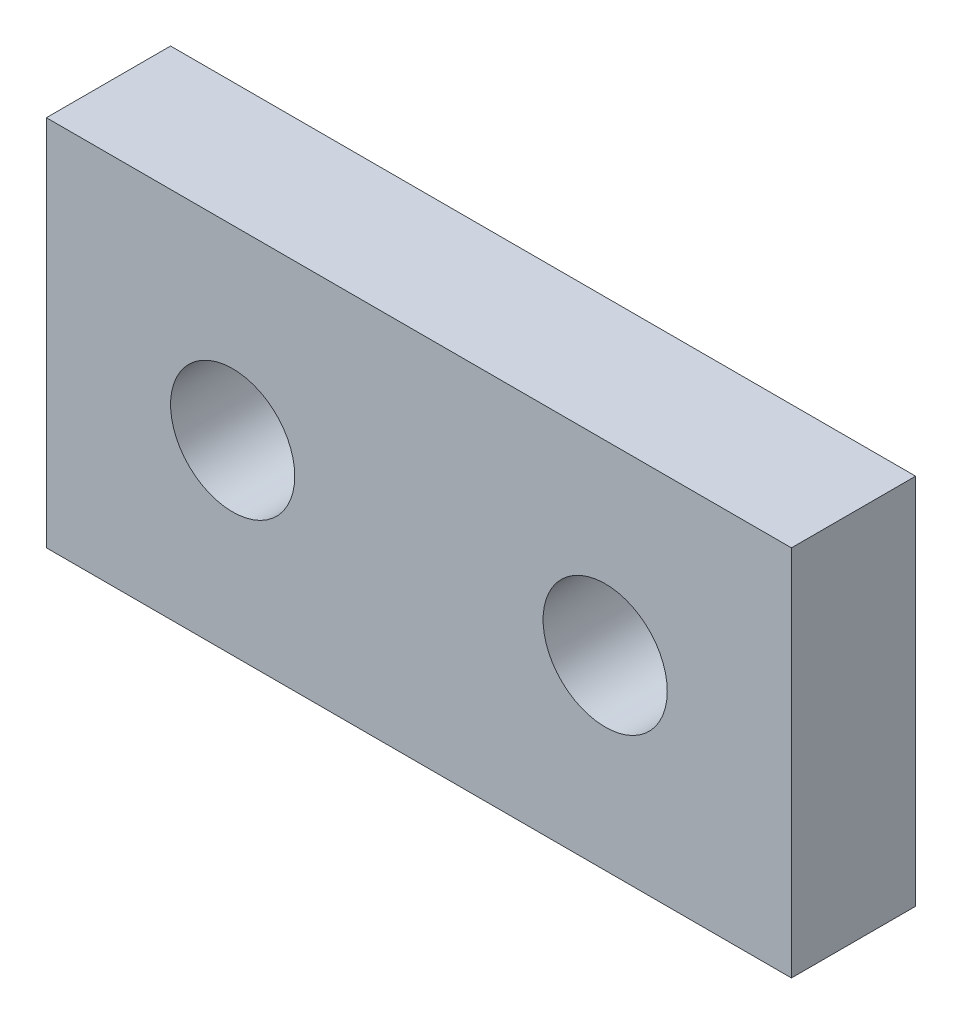
from build123d import *

# Parameters (mm, degrees)
SKETCH1_W           = 60
SKETCH1_H           = 30
SKETCH1_R           = 5
BOSS_EXTRUDE1_DEPTH = 10


with BuildPart() as part:
    # Sketch1 → Boss-Extrude1 (new body)
    with BuildSketch(Plane.XY):
        with Locations((30, 15)):
            Rectangle(SKETCH1_W, SKETCH1_H)
        with Locations((15, 15)):
            Circle(SKETCH1_R, mode=Mode.SUBTRACT)
        with Locations((45, 15)):
            Circle(SKETCH1_R, mode=Mode.SUBTRACT)
    extrude(amount=BOSS_EXTRUDE1_DEPTH)


solid = part.part
